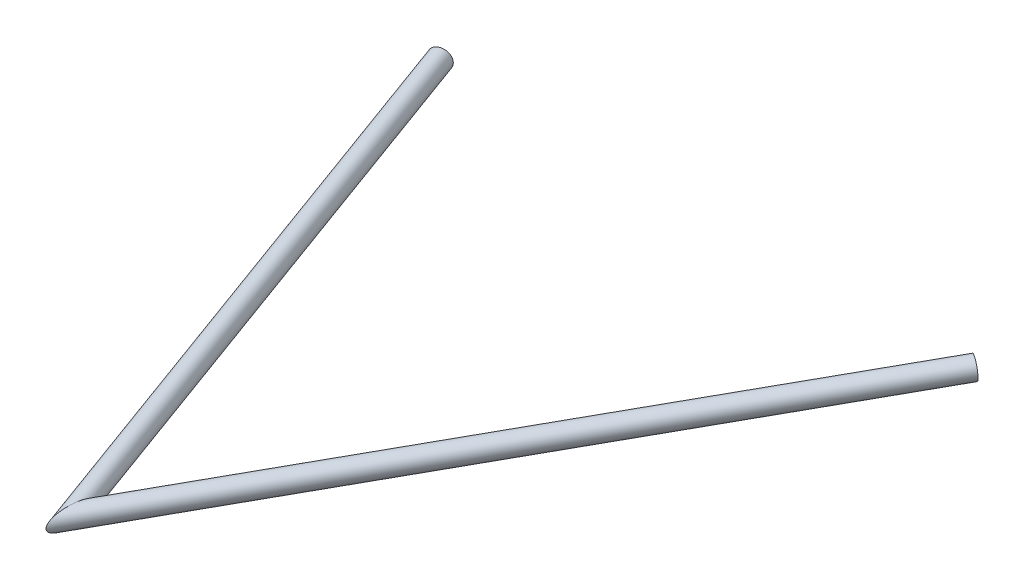
from build123d import *

# Parameters (mm, degrees)
SKETCH1_ON_SEGMENT_1_R                         = 9.525
SKETCH1_ON_SEGMENT_1_R_2                       = 6.985
PIPE_STANDARD_S40_PIPE_1_SCH_40_5_DEPTH        = 638.812049493
SKETCH1_R                                      = 9.525
SKETCH1_R_2                                    = 6.985
PIPE_STANDARD_S40_PIPE_1_SCH_40_5_2_DEPTH      = 537.731427899
PIPE_STANDARD_S40_PIPE_1_SCH_40_5_2_DEPTH_BACK = 29.186654936


with BuildPart() as part:
    # Sketch1 on segment 1 (carried to segment 1) → Pipe standard s40 PIPE 1 SCH 40_5 (new body)
    with BuildSketch(Plane(origin=(315.563263322, 0, -538.649609422), x_dir=(0.780565152, 0.334231479, 0.528211474), z_dir=(-0.544828119, -0.050429144, 0.837030001))):
        Circle(SKETCH1_ON_SEGMENT_1_R)
        Circle(SKETCH1_ON_SEGMENT_1_R_2, mode=Mode.SUBTRACT)
    extrude(amount=PIPE_STANDARD_S40_PIPE_1_SCH_40_5_DEPTH)

    # Pipe standard s40 PIPE 1 SCH 40_5 mitre
    split(bisect_by=Plane(origin=(-16.577793594, -30.742886911, -28.374864893), x_dir=(0.007884929, 0.999968913, 0), z_dir=(0.991513492, -0.007818257, 0.129768522)), keep=Keep.TOP)


with BuildPart() as body_2:
    # Sketch1 → Pipe standard s40 PIPE 1 SCH 40_5 2 (new, two sides)
    with BuildSketch(Plane(origin=(-16.577793594, -30.742886911, -28.374864893), x_dir=(-0.8849256600733008, 0.3473641648259723, 0.31023332048409596), z_dir=(-0.3102333204840959, 0.057171452728250034, -0.9489397830496694))) as pipe_standard_s40_pipe_1_sch_40_5_2_sk:
        Circle(SKETCH1_R)
        Circle(SKETCH1_R_2, mode=Mode.SUBTRACT)
    extrude(amount=PIPE_STANDARD_S40_PIPE_1_SCH_40_5_2_DEPTH)
    extrude(pipe_standard_s40_pipe_1_sch_40_5_2_sk.sketch, amount=-PIPE_STANDARD_S40_PIPE_1_SCH_40_5_2_DEPTH_BACK)

    # Pipe standard s40 PIPE 1 SCH 40_5 2 mitr
    split(bisect_by=Plane(origin=(-16.577793594, -30.742886911, -28.374864893), x_dir=(-0.007884929, -0.999968913, 0), z_dir=(-0.991513492, 0.007818257, -0.129768522)), keep=Keep.TOP)


solid = Compound([part.part, body_2.part])
